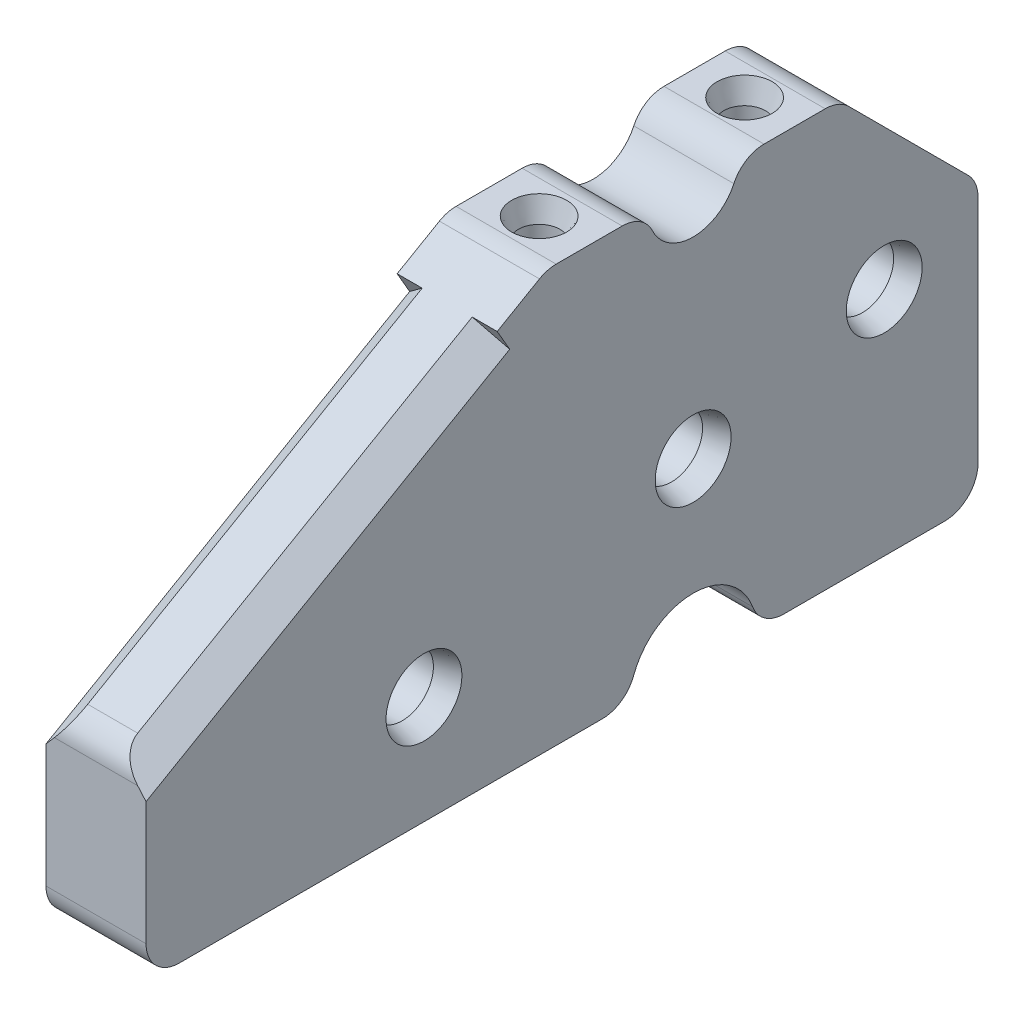
from build123d import *

# Parameters (mm, degrees)
BOSS_EXTRUDE1_DEPTH     = 3.81
SKETCH2_R               = 2.38125
CUT_EXTRUDE1_DEPTH      = 8.62
CHAMFER1_SIZE           = 0.508
CHAMFER1_SIZE2          = 1.66159313
CHAMFER2_SIZE           = 0.508
CHAMFER2_SIZE2          = 1.66159313
CHAMFER3_SIZE           = 0.508
CHAMFER3_SIZE2          = 1.66159313
CHAMFER4_SIZE           = 0.508
CHAMFER4_SIZE2          = 1.66159313
SKETCH3_R               = 1.5875
CUT_EXTRUDE2_DEPTH      = 12.7
CHAMFER5_SIZE           = 0.508
CHAMFER5_SIZE2          = 1.66159313
CHAMFER5_PART_2_SIZE    = 0.508
CHAMFER5_PART_2_SIZE2   = 1.66159313
SKETCH4_R               = 4.826
CUT_EXTRUDE3_DEPTH      = 8.62
FILLET1_R               = 2.54
SKETCH5_R               = 1.830021078
SKETCH5_R_2             = 1.859210554
CUT_EXTRUDE4_DEPTH      = 12.7
CHAMFER6_SIZE           = 0.508
CHAMFER6_SIZE2          = 1.66159313
CHAMFER6_PART_2_SIZE    = 0.508
CHAMFER6_PART_2_SIZE2   = 1.66159313
CUT_EXTRUDE7_START      = 10.16
CUT_EXTRUDE7_DEPTH      = 42.745681687
CUT_EXTRUDE7_DEPTH_BACK = 6.35


with BuildPart() as part:
    # Sketch1 → Boss-Extrude1 (new body, symmetric)
    with BuildSketch(Plane(origin=(0, 0, 0), x_dir=(0, 0, -1), z_dir=(1, 0, 0))):
        with BuildLine():
            Line((-5.401607261, 20.422717891), (-10.431909051, 20.422717891))
            ThreePointArc((-10.431909051, 20.422717891), (-11.089309426, 20.33616949), (-11.701909051, 20.082422416))
            Line((-11.701909051, 20.082422416), (-40.393951745, 3.517063844))
            ThreePointArc((-40.393951745, 3.517063844), (-41.32365627, 2.587359318), (-41.663951745, 1.317359318))
            Line((-41.663951745, 1.317359318), (-41.663951745, -8.787282109))
            ThreePointArc((-41.663951745, -8.787282109), (-40.920002969, -10.583333333), (-39.123951745, -11.327282109))
            Line((-39.123951745, -11.327282109), (19.155833333, -11.327282109))
            ThreePointArc((19.155833333, -11.327282109), (20.951884558, -10.583333333), (21.695833333, -8.787282109))
            Line((21.695833333, -8.787282109), (21.695833333, 8.787282109))
            ThreePointArc((21.695833333, 8.787282109), (21.502487346, 9.759298027), (20.951884558, 10.583333333))
            Line((20.951884558, 10.583333333), (11.856448776, 19.678769115))
            ThreePointArc((11.856448776, 19.678769115), (11.03241347, 20.229371903), (10.060397552, 20.422717891))
            Line((10.060397552, 20.422717891), (5.401607261, 20.422717891))
            ThreePointArc((5.401607261, 20.422717891), (4.040314071, 20.027124767), (3.10305098, 18.963568955))
            ThreePointArc((3.10305098, 18.963568955), (0, 16.993717891), (-3.10305098, 18.963568955))
            ThreePointArc((-3.10305098, 18.963568955), (-4.040314071, 20.027124767), (-5.401607261, 20.422717891))
        make_face()
    extrude(amount=BOSS_EXTRUDE1_DEPTH, both=True)

    # Sketch2 → Cut-Extrude1 (cut, through all)
    with BuildSketch(Plane(origin=(3.81, 0, 0), x_dir=(0, 0, -1), z_dir=(1, 0, 0))):
        with Locations((14.552083333, 6.275759092)):
            Circle(SKETCH2_R)
        with Locations((0, 2.376540114)):
            Circle(SKETCH2_R)
        with Locations((-20.497285078, -3.115690869)):
            Circle(SKETCH2_R)
    extrude(amount=-CUT_EXTRUDE1_DEPTH, mode=Mode.SUBTRACT)

    # Chamfer1
    chamfer1_edges = [part.edges().sort_by_distance(p)[0] for p in [
        (3.81, 6.275759092, -12.170833333),
        (3.81, 2.376540114, 2.38125),
        (3.81, -3.115690869, 22.878535078),
    ]]
    chamfer1_side = [part.faces().sort_by_distance(p)[0] for p in [
        (3.81, 2.381626515, 7.750929536),
    ]]
    chamfer(chamfer1_edges, length=CHAMFER1_SIZE, length2=CHAMFER1_SIZE2, reference=chamfer1_side[0])

    # Chamfer2
    chamfer2_edges = [part.edges().sort_by_distance(p)[0] for p in [
        (-3.81, -3.115690869, 22.878535078),
    ]]
    chamfer2_side = [part.faces().sort_by_distance(p)[0] for p in [
        (-3.81, 2.381626515, 7.750929536),
    ]]
    chamfer(chamfer2_edges, length=CHAMFER2_SIZE, length2=CHAMFER2_SIZE2, reference=chamfer2_side[0])

    # Chamfer3
    chamfer3_edges = [part.edges().sort_by_distance(p)[0] for p in [
        (-3.81, 2.376540114, 2.38125),
    ]]
    chamfer3_side = [part.faces().sort_by_distance(p)[0] for p in [
        (-3.81, 2.410504504, 7.683971585),
    ]]
    chamfer(chamfer3_edges, length=CHAMFER3_SIZE, length2=CHAMFER3_SIZE2, reference=chamfer3_side[0])

    # Chamfer4
    chamfer4_edges = [part.edges().sort_by_distance(p)[0] for p in [
        (-3.81, 6.275759092, -12.170833333),
    ]]
    chamfer4_side = [part.faces().sort_by_distance(p)[0] for p in [
        (-3.81, 2.410683864, 7.724549459),
    ]]
    chamfer(chamfer4_edges, length=CHAMFER4_SIZE, length2=CHAMFER4_SIZE2, reference=chamfer4_side[0])

    # Sketch3 → Cut-Extrude2 (cut)
    with BuildSketch(Plane(origin=(0, 20.422717891, 0), x_dir=(1, 0, 0), z_dir=(0, 1, 0))):
        with Locations((0, -7.916758156)):
            Circle(SKETCH3_R)
        with Locations((0, 7.731002406)):
            Circle(SKETCH3_R)
    extrude(amount=-CUT_EXTRUDE2_DEPTH, mode=Mode.SUBTRACT)

    # Chamfer5
    chamfer5_edges = [part.edges().sort_by_distance(p)[0] for p in [
        (-1.5875, 20.422717891, 7.916758156),
    ]]
    chamfer5_side = [part.faces().sort_by_distance(p)[0] for p in [
        (0, 20.422717891, 5.492913524),
    ]]
    chamfer(chamfer5_edges, length=CHAMFER5_SIZE, length2=CHAMFER5_SIZE2, reference=chamfer5_side[0])

    # Chamfer5 part 2
    chamfer5_part_2_edges = [part.edges().sort_by_distance(p)[0] for p in [
        (-1.5875, 20.422717891, -7.731002406),
    ]]
    chamfer5_part_2_side = [part.faces().sort_by_distance(p)[0] for p in [
        (0, 20.422717891, -9.971084212),
    ]]
    chamfer(chamfer5_part_2_edges, length=CHAMFER5_PART_2_SIZE, length2=CHAMFER5_PART_2_SIZE2, reference=chamfer5_part_2_side[0])

    # Sketch4 → Cut-Extrude3 (cut, through all)
    with BuildSketch(Plane.ZY.offset(3.81)):
        with Locations((0, -11.327282109)):
            Circle(SKETCH4_R)
    extrude(amount=-CUT_EXTRUDE3_DEPTH, mode=Mode.SUBTRACT)

    # Fillet1
    fillet1_edges = [part.edges().sort_by_distance(p)[0] for p in [
        (0, -11.327282109, -4.826),
        (0, -11.327282109, 4.826),
    ]]
    fillet(fillet1_edges, radius=FILLET1_R)

    # Sketch5 → Cut-Extrude4 (cut)
    with BuildSketch(Plane.XZ.offset(11.327282109)):
        with Locations((0, -13.035023694)):
            Circle(SKETCH5_R)
        with Locations((0, 13.035023694)):
            Circle(SKETCH5_R_2)
    extrude(amount=-CUT_EXTRUDE4_DEPTH, mode=Mode.SUBTRACT)

    # Chamfer6
    chamfer6_edges = [part.edges().sort_by_distance(p)[0] for p in [
        (-1.830021078, -11.327282109, -13.035023694),
    ]]
    chamfer6_side = [part.faces().sort_by_distance(p)[0] for p in [
        (3.665805117, -11.327282109, -13.035023694),
    ]]
    chamfer(chamfer6_edges, length=CHAMFER6_SIZE, length2=CHAMFER6_SIZE2, reference=chamfer6_side[0])

    # Chamfer6 part 2
    chamfer6_part_2_edges = [part.edges().sort_by_distance(p)[0] for p in [
        (-1.859210554, -11.327282109, 13.035023694),
    ]]
    chamfer6_part_2_side = [part.faces().sort_by_distance(p)[0] for p in [
        (0, -11.327282109, 23.481278136),
    ]]
    chamfer(chamfer6_part_2_edges, length=CHAMFER6_PART_2_SIZE, length2=CHAMFER6_PART_2_SIZE2, reference=chamfer6_part_2_side[0])

    # Sketch7 → Cut-Extrude7 (cut, two sides)
    with BuildSketch(Plane(origin=(0, 0, 0), x_dir=(1, 0, 0), z_dir=(0, -0.5, 0.866025404)).offset(CUT_EXTRUDE7_START)) as cut_extrude7_sk:
        Polygon((-10.16, 27.687842508), (10.16, 27.687842508), (10.16, 14.987842508), (0, 25.147842508), (-10.16, 14.987842508), align=None)
    extrude(amount=CUT_EXTRUDE7_DEPTH, mode=Mode.SUBTRACT)
    extrude(cut_extrude7_sk.sketch, amount=-CUT_EXTRUDE7_DEPTH_BACK, mode=Mode.SUBTRACT)


solid = part.part
